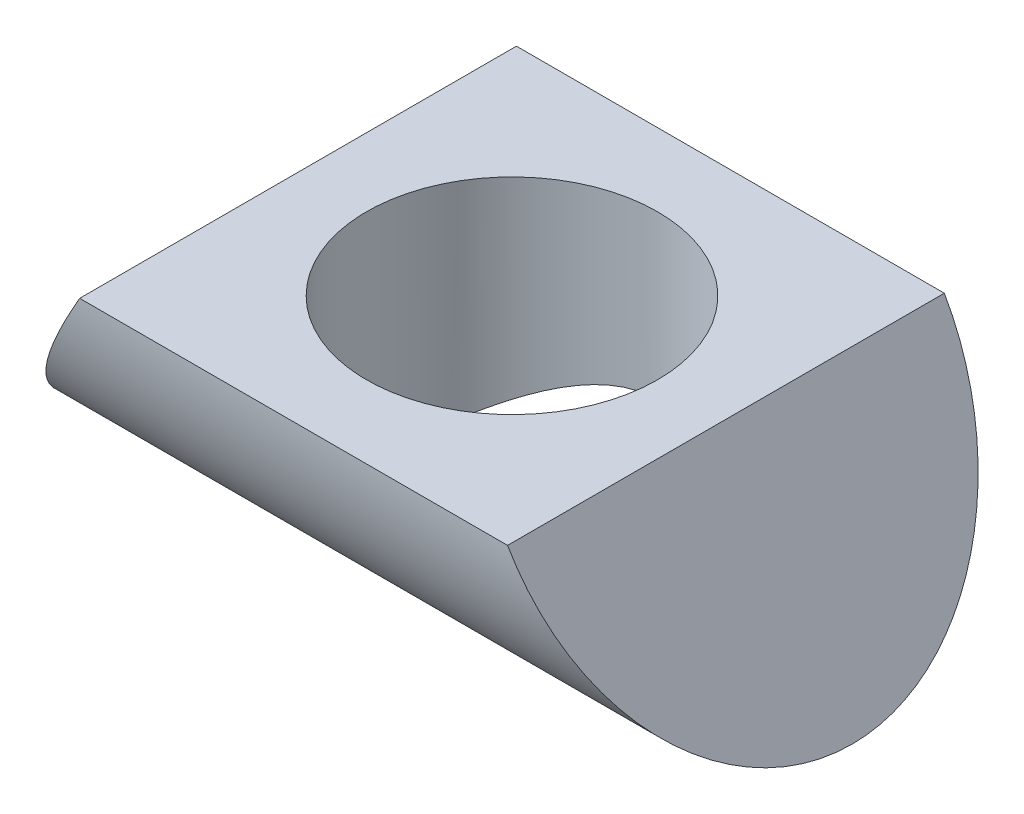
from build123d import *

# Parameters (mm, degrees)
BOSS_EXTRUDE3_DEPTH      = 34
BOSS_EXTRUDE3_DEPTH_BACK = 34
SKETCH1_R                = 4.7625
CUT_EXTRUDE1_DEPTH       = 36.469734281
CUT_EXTRUDE3_DEPTH       = 36.46973442
CUT_EXTRUDE3_DEPTH_BACK  = 36.46973442


with BuildPart() as part:
    # Sketch2 → Boss-Extrude3 (new, two sides: drawn at the far end of the back side and taken through both)
    with BuildSketch(Plane(origin=(0, 0, 0), x_dir=(0, 0, -1), z_dir=(1, 0, 0)).offset(-BOSS_EXTRUDE3_DEPTH_BACK)):
        with BuildLine():
            Line((-7.145, 0), (7.145, 0))
            ThreePointArc((7.145, 0), (0, -7.145), (-7.145, 0))
        make_face()
    extrude(amount=BOSS_EXTRUDE3_DEPTH + BOSS_EXTRUDE3_DEPTH_BACK)

    # Sketch1 → Cut-Extrude1 (cut, through all)
    with BuildSketch(Plane(origin=(0, 0, 0), x_dir=(1, 0, 0), z_dir=(0, 1, 0))):
        with Locations((-20, 0)):
            Circle(SKETCH1_R)
        with Locations((20, 0)):
            Circle(SKETCH1_R)
    extrude(amount=-CUT_EXTRUDE1_DEPTH, mode=Mode.SUBTRACT)

    # Sketch4 → Cut-Extrude3 (cut, two sides: drawn at the far end of the back side and taken through both)
    with BuildSketch(Plane.XY.offset(-CUT_EXTRUDE3_DEPTH_BACK)):
        Polygon((-13, 0), (13, 0), (7.803847577, -9), (-7.803847577, -9), align=None)
        Polygon((32.196152423, -9), (43.216463998, -9), (43.216463998, 0), (27, 0), align=None)
        Polygon((-43.216463998, 0), (-27, 0), (-32.196152423, -9), (-43.216463998, -9), align=None)
    extrude(amount=CUT_EXTRUDE3_DEPTH + CUT_EXTRUDE3_DEPTH_BACK, mode=Mode.SUBTRACT)


with BuildPart() as cut_extrude3_piece_1:
    # of the separate pieces the step leaves, piece 1, a body of its own (cut_extrude3_pieces)
    add(part.part.solids().sort_by_distance((-27, 0, 7.145))[0])


with BuildPart() as cut_extrude3_piece_2:
    # of the separate pieces the step leaves, piece 2, a body of its own (cut_extrude3_pieces)
    add(part.part.solids().sort_by_distance((13, 0, 7.145))[0])


solid = cut_extrude3_piece_2.part
